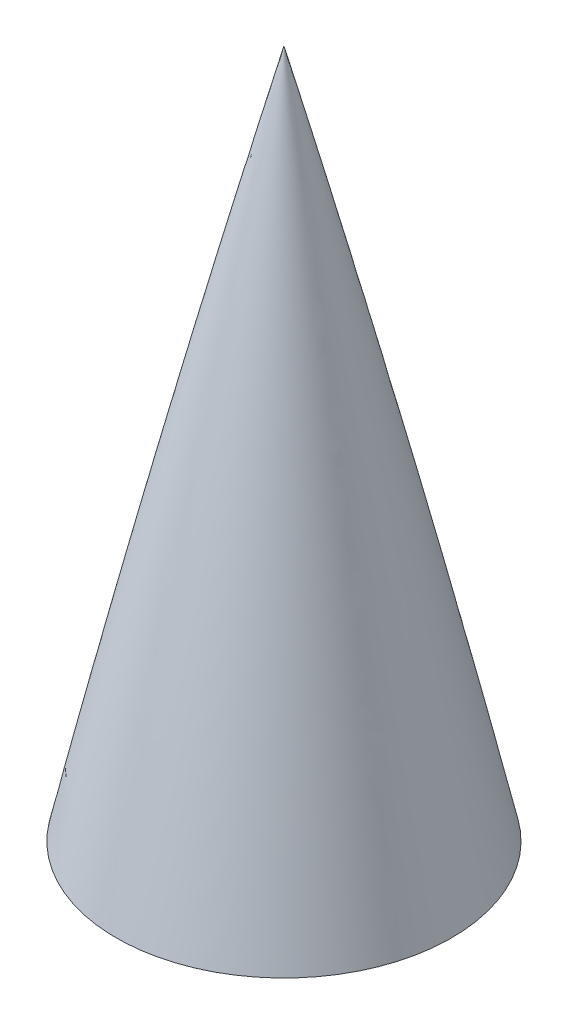
from build123d import *


with BuildPart() as part:
    # Sketch1 → Revolve1 (revolve)
    with BuildSketch(Plane.XY):
        with BuildLine():
            Line((0, 0), (0, 76.2))
            ThreePointArc((0, 76.2), (9.651782653, 38.191542467), (18.551548743, 0))
            Line((18.551548743, 0), (0, 0))
        make_face()
    revolve(axis=Axis((0, 0, 0), (0, 1, 0)))


solid = part.part
